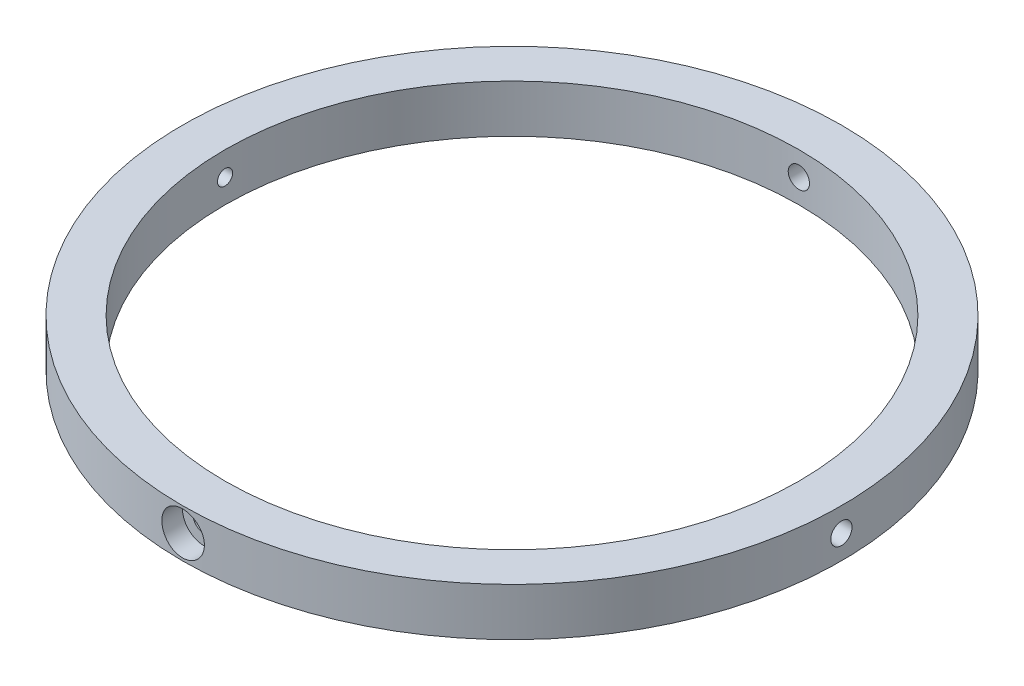
from build123d import *

# Parameters (mm, degrees)
SKETCH1_R           = 49.2125
SKETCH1_R_2         = 42.8625
BOSS_EXTRUDE1_DEPTH = 3.571875
HOLE2_D             = 3.175
HOLE2_DEPTH         = 2.38125
HOLE1_D             = 3.175
HOLE1_DEPTH         = 12.7
HOLE1_CBORE_D       = 6.35
HOLE1_CBORE_DEPTH   = 3.175
CIRPATTERN1_COUNT   = 2


with BuildPart() as part:
    # Sketch1 → Boss-Extrude1 (new body, symmetric)
    with BuildSketch(Plane(origin=(0, 0, 0), x_dir=(1, 0, 0), z_dir=(0, 1, 0))):
        Circle(SKETCH1_R)
        Circle(SKETCH1_R_2, mode=Mode.SUBTRACT)
    extrude(amount=BOSS_EXTRUDE1_DEPTH, both=True)

    # Hole2
    with Locations(Plane(origin=(49.2125, 0, 0), x_dir=(0, 0, 1), z_dir=(1, 0, 0))):
        with Locations((0, 0)):
            hole2 = Hole(HOLE2_D / 2, depth=HOLE2_DEPTH)

    # Sketch7 → #4-40 Tapped Hole1 (revolve, cut)
    with BuildSketch(Plane(origin=(46.83125, 0, 0), x_dir=(0, 0, -1), z_dir=(0, 1, 0))):
        Polygon((0, 0), (0, 9.569152758), (1.1303, 8.89), (1.1303, 0), align=None)
    f_4_40_tapped_hole1 = revolve(axis=Axis((53.18125, 0, 0), (-1, 0, 0)), mode=Mode.SUBTRACT)

    # Hole1
    with Locations(Plane(origin=(0, 0, -49.2125), x_dir=(-1, 0, 0), z_dir=(0, 0, -1))):
        with Locations((0, 0)):
            hole1 = CounterBoreHole(HOLE1_D / 2, HOLE1_CBORE_D / 2, HOLE1_CBORE_DEPTH, depth=HOLE1_DEPTH)

    # CirPattern1: Hole2, #4-40 Tapped Hole1, Hole1 ×2 about axis
    cirpattern1_axis = Axis((0, 0, 0), (0, 1, 0))
    for i in range(1, CIRPATTERN1_COUNT):
        add(hole2.rotate(cirpattern1_axis, i * 360 / CIRPATTERN1_COUNT), mode=Mode.SUBTRACT)
        add(f_4_40_tapped_hole1.rotate(cirpattern1_axis, i * 360 / CIRPATTERN1_COUNT), mode=Mode.SUBTRACT)
        add(hole1.rotate(cirpattern1_axis, i * 360 / CIRPATTERN1_COUNT), mode=Mode.SUBTRACT)


solid = part.part
